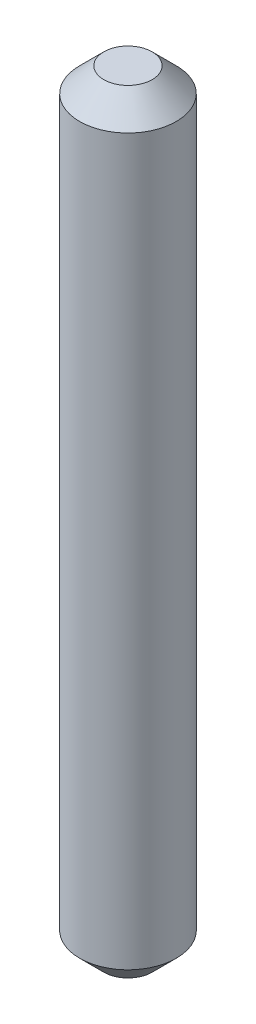
from build123d import *

# Parameters (mm, degrees)
SKETCH1_R           = 0.5
BOSS_EXTRUDE1_DEPTH = 8
CHAMFER1_SIZE       = 0.25


with BuildPart() as part:
    # Sketch1 → Boss-Extrude1 (new body)
    with BuildSketch(Plane(origin=(0, 0, 0), x_dir=(1, 0, 0), z_dir=(0, 1, 0))):
        Circle(SKETCH1_R)
    extrude(amount=BOSS_EXTRUDE1_DEPTH)

    # Chamfer1
    chamfer1_edges = [part.edges().sort_by_distance(p)[0] for p in [
        (-0.5, 0, 0),
        (-0.5, 8, 0),
    ]]
    chamfer(chamfer1_edges, length=CHAMFER1_SIZE)


solid = part.part
